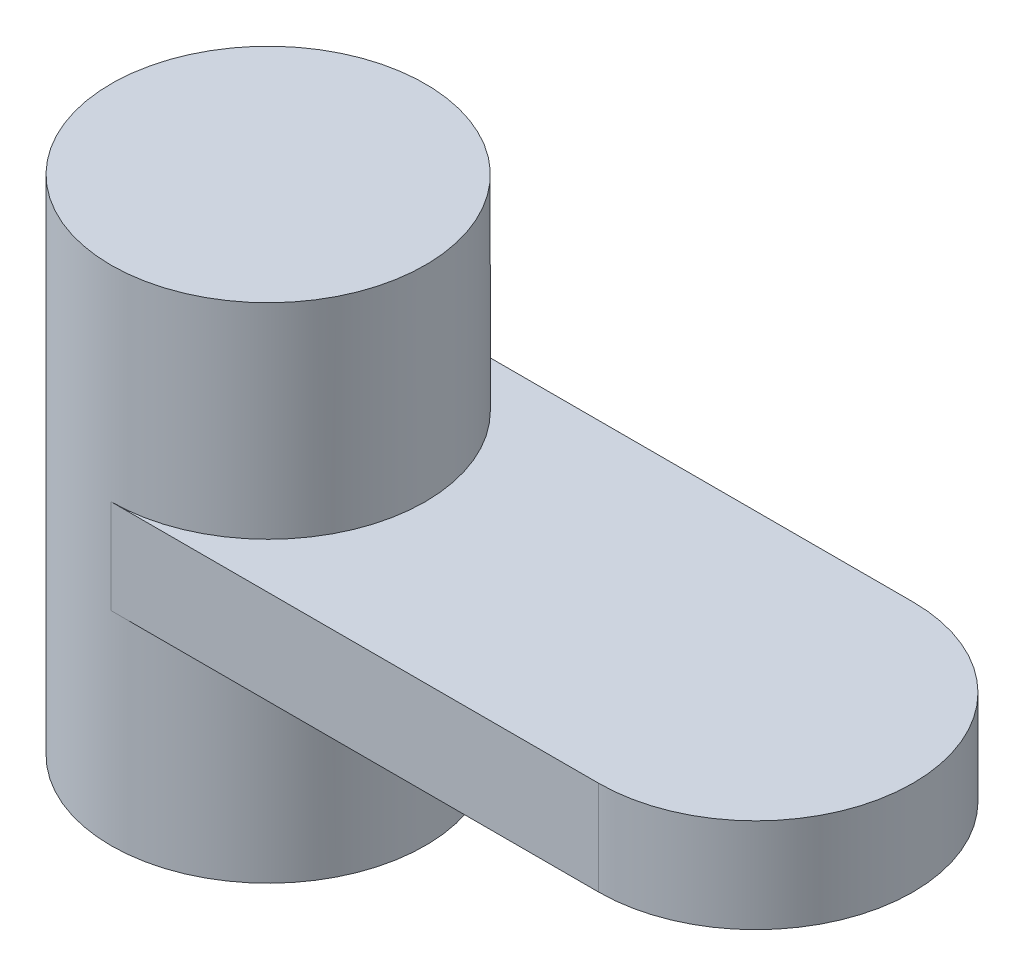
from build123d import *

# Parameters (mm, degrees)
BOSS_EXTRUDE1_DEPTH      = 19.05
SKETCH3_R                = 31.75
BOSS_EXTRUDE2_DEPTH      = 41.402
BOSS_EXTRUDE2_DEPTH_BACK = 60.198


with BuildPart() as part:
    # Sketch1 → Boss-Extrude1 (new body)
    with BuildSketch(Plane(origin=(0, 0, 0), x_dir=(1, 0, 0), z_dir=(0, 1, 0))):
        with BuildLine():
            Line((-49.276, 31.75), (49.276, 31.75))
            ThreePointArc((49.276, 31.75), (81.026, 0), (49.276, -31.75))
            Line((49.276, -31.75), (-49.276, -31.75))
            ThreePointArc((-49.276, -31.75), (-81.026, 0), (-49.276, 31.75))
        make_face()
    extrude(amount=BOSS_EXTRUDE1_DEPTH)

    # Sketch3 → Boss-Extrude2 (add, two sides)
    with BuildSketch(Plane(origin=(0, 19.05, 0), x_dir=(1, 0, 0), z_dir=(0, 1, 0))) as boss_extrude2_sk:
        with Locations(Location((-49.276, 0, 0), (0, 0, 270))):  # turned: the seam where the file's is
            Circle(SKETCH3_R)
    extrude(amount=BOSS_EXTRUDE2_DEPTH)
    extrude(boss_extrude2_sk.sketch, amount=-BOSS_EXTRUDE2_DEPTH_BACK)


solid = part.part
